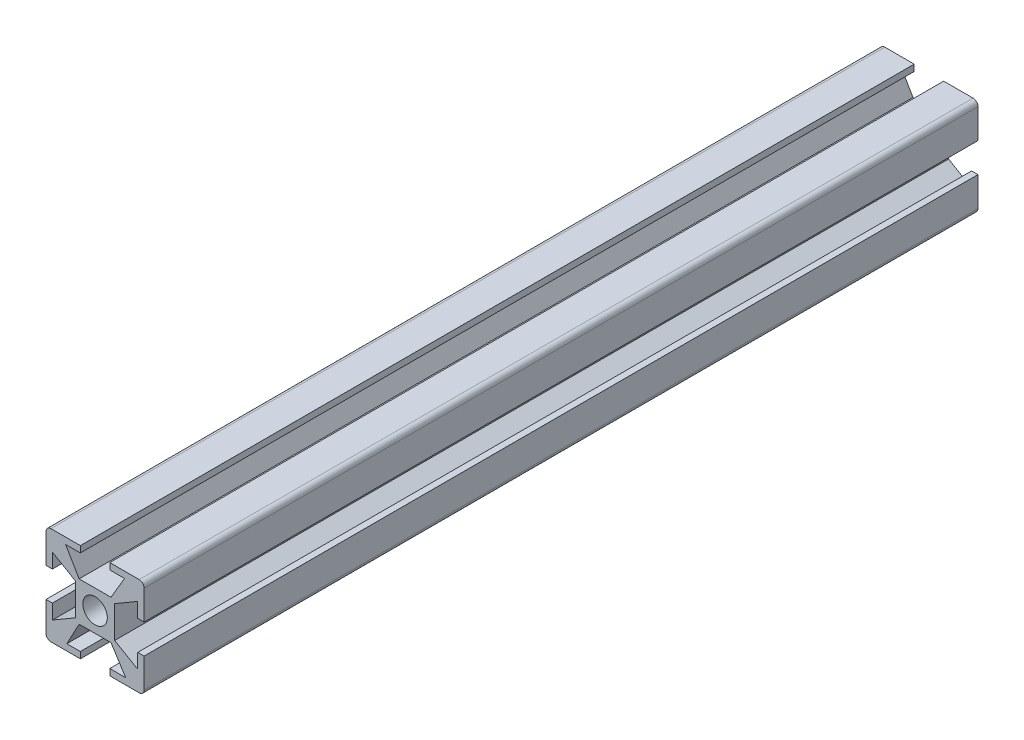
from build123d import *

# Parameters (mm, degrees)
CROQUIS1_W              = 8
CROQUIS1_H              = 8
CROQUIS1_R              = 2.5
SALIENTE_EXTRUIR4_DEPTH = 170


with BuildPart() as part:
    # Croquis1 → Saliente-Extruir4 (new body)
    with BuildSketch(Plane.XY):
        with BuildLine():
            Line((-3, 8.7), (-3, 10))
            Line((-3, 10), (-9, 10))
            ThreePointArc((-9, 10), (-9.707106781, 9.707106781), (-10, 9))
            Line((-10, 9), (-10, 3))
            Line((-10, 3), (-8.7, 3))
            Line((-8.7, 3), (-8.7, 6))
            Line((-8.7, 6), (-4, 3.25))
            Line((-4, 3.25), (-4, 4))
            Line((-4, 4), (-3.25, 4))
            Line((-3.25, 4), (-6, 8.7))
            Line((-6, 8.7), (-3, 8.7))
        make_face()
        with BuildLine():
            Line((9, 10), (3, 10))
            Line((3, 10), (3, 8.7))
            Line((3, 8.7), (6, 8.7))
            Line((6, 8.7), (3.25, 4))
            Line((3.25, 4), (4, 4))
            Line((4, 4), (4, 3.25))
            Line((4, 3.25), (8.7, 6))
            Line((8.7, 6), (8.7, 3))
            Line((8.7, 3), (10, 3))
            Line((10, 3), (10, 9))
            ThreePointArc((10, 9), (9.707106781, 9.707106781), (9, 10))
        make_face()
        with BuildLine():
            Line((10, -9), (10, -3))
            Line((10, -3), (8.7, -3))
            Line((8.7, -3), (8.7, -6))
            Line((8.7, -6), (4, -3.25))
            Line((4, -3.25), (4, -4))
            Line((4, -4), (3.25, -4))
            Line((3.25, -4), (6.25, -8.7))
            Line((6.25, -8.7), (3, -8.7))
            Line((3, -8.7), (3, -10))
            Line((3, -10), (9, -10))
            ThreePointArc((9, -10), (9.707106781, -9.707106781), (10, -9))
        make_face()
        with BuildLine():
            Line((-8.7, -3), (-10, -3))
            Line((-10, -3), (-10, -9))
            ThreePointArc((-10, -9), (-9.707106781, -9.707106781), (-9, -10))
            Line((-9, -10), (-3, -10))
            Line((-3, -10), (-3, -8.7))
            Line((-3, -8.7), (-5.75, -8.7))
            Line((-5.75, -8.7), (-3.25, -4))
            Line((-3.25, -4), (-4, -4))
            Line((-4, -4), (-4, -3.25))
            Line((-4, -3.25), (-8.7, -6))
            Line((-8.7, -6), (-8.7, -3))
        make_face()
        Rectangle(CROQUIS1_W, CROQUIS1_H)
        Circle(CROQUIS1_R, mode=Mode.SUBTRACT)
    extrude(amount=SALIENTE_EXTRUIR4_DEPTH)


solid = part.part
